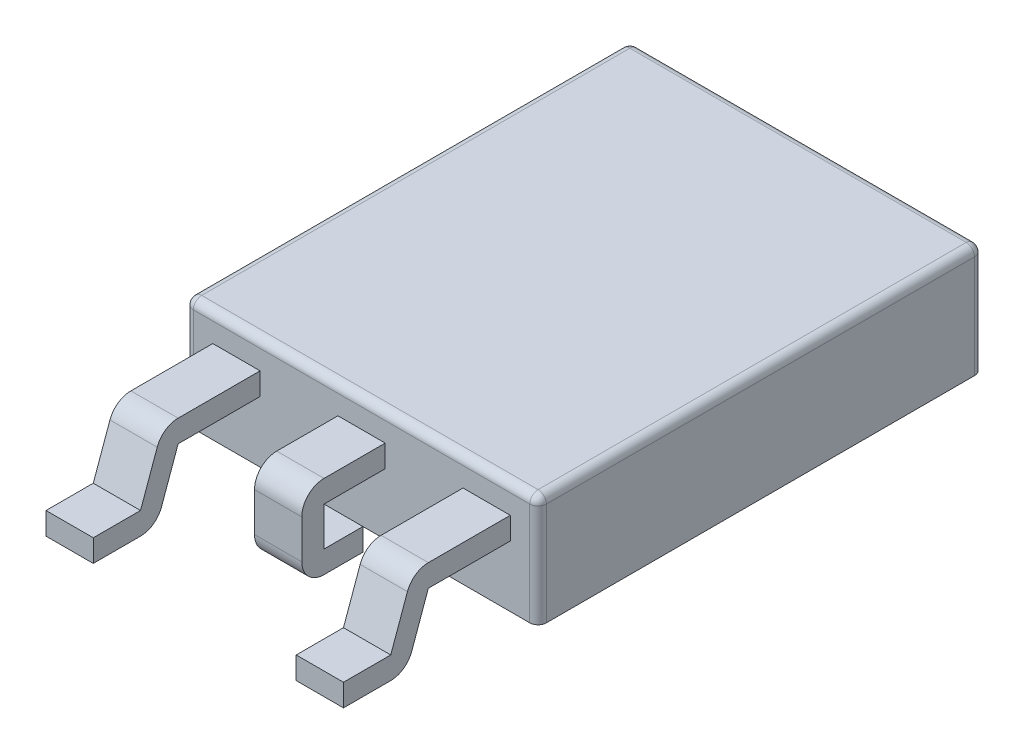
from build123d import *

# Parameters (mm, degrees)
SKETCH1_W           = 6.35
SKETCH1_H           = 8
BOSS_EXTRUDE1_DEPTH = 2
FILLET1_R           = 0.15
BOSS_EXTRUDE2_DEPTH = 0.425
BOSS_EXTRUDE3_START = -0.5
BOSS_EXTRUDE3_DEPTH = 0.85


with BuildPart() as part:
    # Sketch1 → Boss-Extrude1 (new body)
    with BuildSketch(Plane(origin=(0, 0, 0), x_dir=(1, 0, 0), z_dir=(0, 1, 0))):
        Rectangle(SKETCH1_W, SKETCH1_H)
    extrude(amount=BOSS_EXTRUDE1_DEPTH)

    # Fillet1
    fillet1_edges = [part.edges().sort_by_distance(p)[0] for p in [
        (3.175, 2, 0),
        (0, 2, -4),
        (-3.175, 2, 0),
        (0, 2, 4),
        (-3.175, 1, -4),
        (3.175, 1, -4),
        (3.175, 1, 4),
        (-3.175, 1, 4),
    ]]
    fillet(fillet1_edges, radius=FILLET1_R)

    # Sketch2 → Boss-Extrude2 (add, symmetric)
    with BuildSketch(Plane(origin=(0, 0, 0), x_dir=(0, 0, -1), z_dir=(1, 0, 0))):
        with BuildLine():
            Line((-4, 1.5), (-5.1, 1.5))
            ThreePointArc((-5.1, 1.5), (-5.382842712, 1.382842712), (-5.5, 1.1))
            Line((-5.5, 1.1), (-5.5, 0.4))
            ThreePointArc((-5.5, 0.4), (-5.382842712, 0.117157288), (-5.1, 0))
            Line((-5.1, 0), (-4.4, 0))
            Line((-4.4, 0), (-4.4, 0.4))
            Line((-4.4, 0.4), (-5.1, 0.4))
            Line((-5.1, 0.4), (-5.1, 1.1))
            Line((-5.1, 1.1), (-4, 1.1))
            Line((-4, 1.1), (-4, 1.5))
        make_face()
    extrude(amount=BOSS_EXTRUDE2_DEPTH, both=True)

    # Sketch3 → Boss-Extrude3 (add)
    with BuildSketch(Plane(origin=(3.175, 0, 0), x_dir=(0, 0, -1), z_dir=(1, 0, 0)).offset(BOSS_EXTRUDE3_START)):
        with BuildLine():
            Line((-4, 1.5), (-5.473547717, 1.5))
            ThreePointArc((-5.473547717, 1.5), (-5.703670661, 1.427174923), (-5.85, 1.235217152))
            Line((-5.85, 1.235217152), (-6.15, 0.4))
            Line((-6.15, 0.4), (-7, 0.4))
            Line((-7, 0.4), (-7, 0))
            Line((-7, 0), (-6.15, 0))
            ThreePointArc((-6.15, 0), (-5.919877056, 0.072825077), (-5.773547717, 0.264782848))
            Line((-5.773547717, 0.264782848), (-5.473547717, 1.1))
            Line((-5.473547717, 1.1), (-4, 1.1))
            Line((-4, 1.1), (-4, 1.5))
        make_face()
    boss_extrude3 = extrude(amount=-BOSS_EXTRUDE3_DEPTH)

    # Mirror1: Boss-Extrude3 across plane
    add(boss_extrude3.mirror(Plane(origin=(0, 0, 0), x_dir=(0, 0, 1), z_dir=(1, 0, 0))))


solid = part.part
